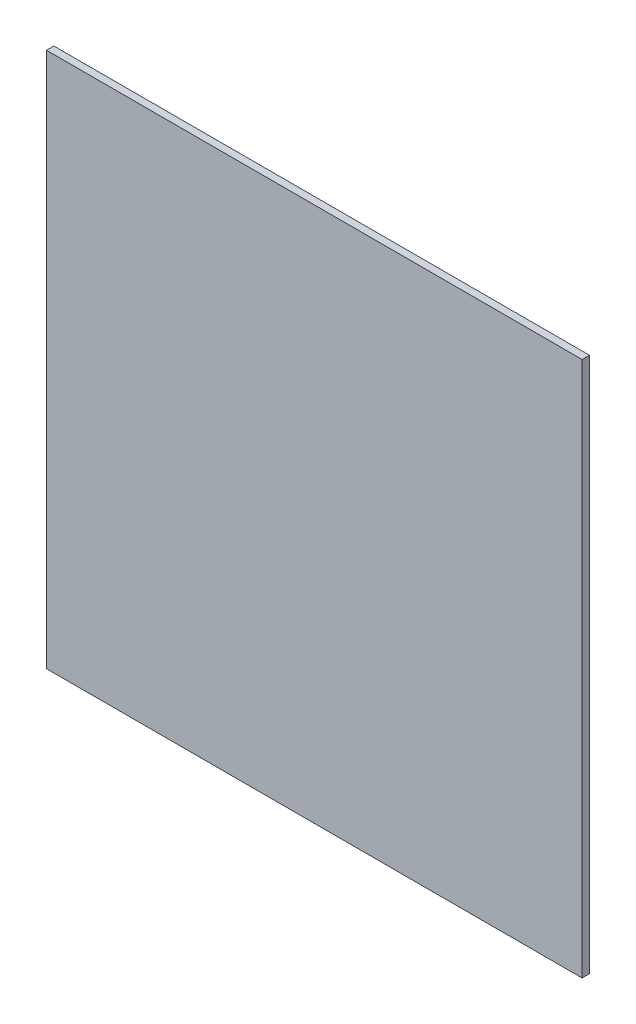
from build123d import *

# Parameters (mm, degrees)
SKETCH_1_W      = 200
SKETCH_1_H      = 200
EXTRUDE_1_DEPTH = 2.75


with BuildPart() as part:
    # 草图1 → 凸台-拉伸1 (new body)
    with BuildSketch(Plane.XY):
        with Locations((100, 100)):
            Rectangle(SKETCH_1_W, SKETCH_1_H)
    extrude(amount=EXTRUDE_1_DEPTH)


solid = part.part
